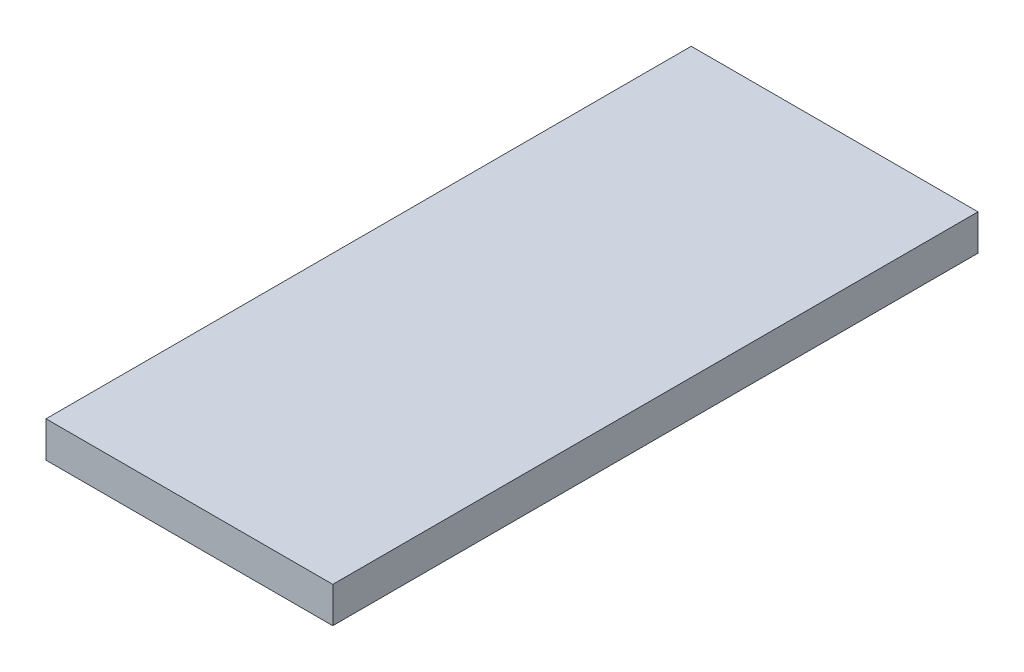
from build123d import *

# Parameters (mm, degrees)
SKETCH1_W           = 90
SKETCH1_H           = 5
BOSS_EXTRUDE1_DEPTH = 40


with BuildPart() as part:
    # Sketch1 → Boss-Extrude1 (new body)
    with BuildSketch(Plane(origin=(0, 0, 0), x_dir=(0, 0, -1), z_dir=(1, 0, 0))):
        with Locations((42.092592593, 0.703703704)):
            Rectangle(SKETCH1_W, SKETCH1_H)
    extrude(amount=BOSS_EXTRUDE1_DEPTH)


solid = part.part
